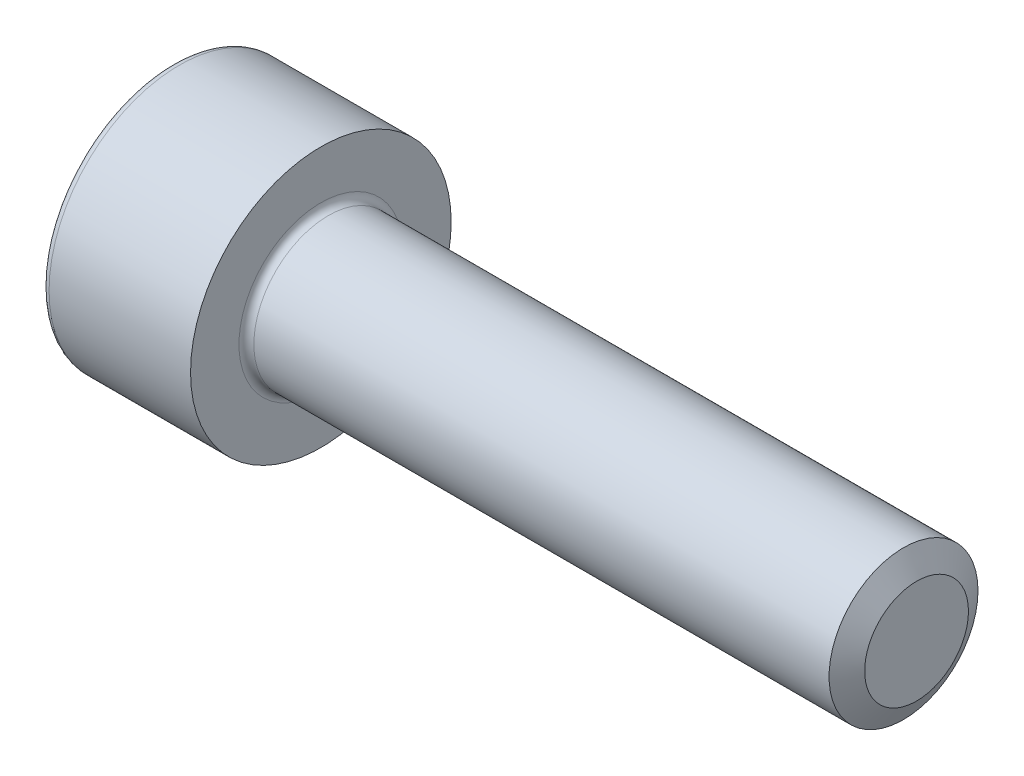
from build123d import *

# Parameters (mm, degrees)
SKETCH_1_W          = 4
SKETCH_1_H          = 3.5
SKETCH_2_R          = 2
EXTRUDE_1_DEPTH     = 16
CUT_EXTRUDE_1_DEPTH = 2
CHAMFER_1_SIZE      = 0.6062
CHAMFER_1_SIZE2     = 0.35
FILLET_1_R          = 0.2


with BuildPart() as part:
    # 草图1 → 旋转1 (revolve)
    with BuildSketch(Plane.XY):
        with Locations((2, 1.75)):
            Rectangle(SKETCH_1_W, SKETCH_1_H)
    revolve(axis=Axis((0, 0, 0), (1, 0, 0)))

    # 草图2 → 凸台-拉伸1 (add)
    with BuildSketch(Plane(origin=(4, 0, 0), x_dir=(0, 0, -1), z_dir=(1, 0, 0))):
        Circle(SKETCH_2_R)
    extrude(amount=EXTRUDE_1_DEPTH)

    # 草图3 → 切除-拉伸1 (cut)
    with BuildSketch(Plane.ZY):
        Polygon((0, 1.72), (-1.489563695, 0.86), (-1.489563695, -0.86), (0, -1.72), (1.489563695, -0.86), (1.489563695, 0.86), align=None)
    extrude(amount=-CUT_EXTRUDE_1_DEPTH, mode=Mode.SUBTRACT)

    # 倒角1
    chamfer_1_edges = [part.edges().sort_by_distance(p)[0] for p in [
        (20, 0, 2),
    ]]
    chamfer_1_side = [part.faces().sort_by_distance(p)[0] for p in [
        (20, 0, 0),
    ]]
    chamfer(chamfer_1_edges, length=CHAMFER_1_SIZE, length2=CHAMFER_1_SIZE2, reference=chamfer_1_side[0])

    # 圆角1
    fillet_1_edges = [part.edges().sort_by_distance(p)[0] for p in [
        (0, -3.5, 0),
        (4, 0, 2),
    ]]
    fillet(fillet_1_edges, radius=FILLET_1_R)


solid = part.part
